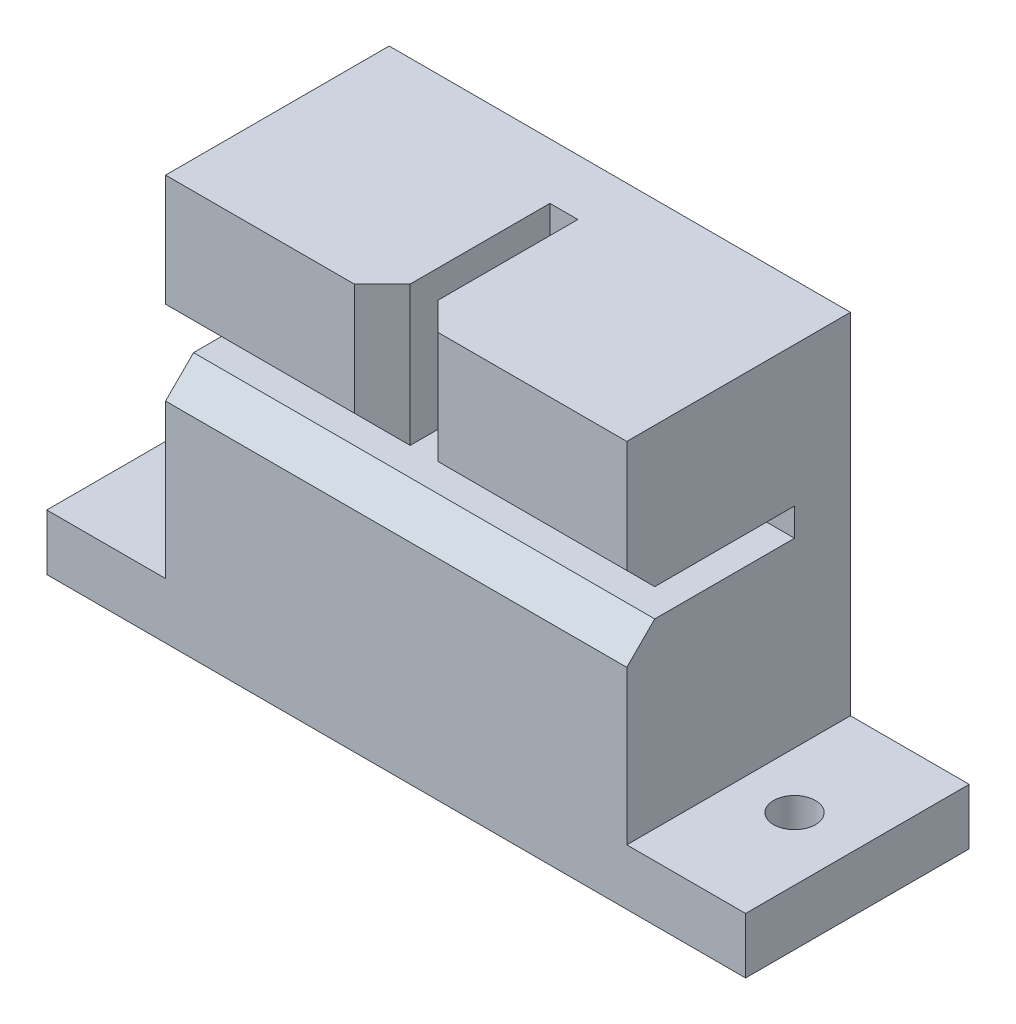
from build123d import *

# Parameters (mm, degrees)
EXTRUDE1_DEPTH = 16
EXTRUDE6_DEPTH = 12
CHAMFER1_SIZE  = 2
SKETCH3_R      = 1.5
EXTRUDE7_DEPTH = 4


with BuildPart() as part:
    # Sketch1 → Extrude1 (new body)
    with BuildSketch(Plane.XY):
        Polygon((16.5, -10.5), (25, -10.5), (25, -14.5), (-25, -14.5), (-25, -10.5), (-16.5, -10.5), (-16.5, 14.5), (16.5, 14.5), align=None)
    extrude(amount=-EXTRUDE1_DEPTH)

    # Sketch2 → Extrude6 (cut)
    with BuildSketch(Plane.XY):
        Polygon((1, 14.5), (-1, 14.5), (-1, 4.5), (-16.5, 4.5), (-16.5, 2.5), (16.5, 2.5), (16.5, 4.5), (1, 4.5), align=None)
    extrude(amount=-EXTRUDE6_DEPTH, mode=Mode.SUBTRACT)

    # Chamfer1
    chamfer1_edges = [part.edges().sort_by_distance(p)[0] for p in [
        (-1, 9.5, 0),
        (8.75, 4.5, 0),
        (-8.75, 4.5, 0),
        (0, 2.5, 0),
        (1, 9.5, 0),
    ]]
    chamfer(chamfer1_edges, length=CHAMFER1_SIZE)

    # Sketch3 → Extrude7 (cut)
    with BuildSketch(Plane.XZ.offset(14.5)):
        with Locations((-20.5, -8)):
            Circle(SKETCH3_R)
        with Locations((20.5, -8)):
            Circle(SKETCH3_R)
    extrude(amount=-EXTRUDE7_DEPTH, mode=Mode.SUBTRACT)


solid = part.part
